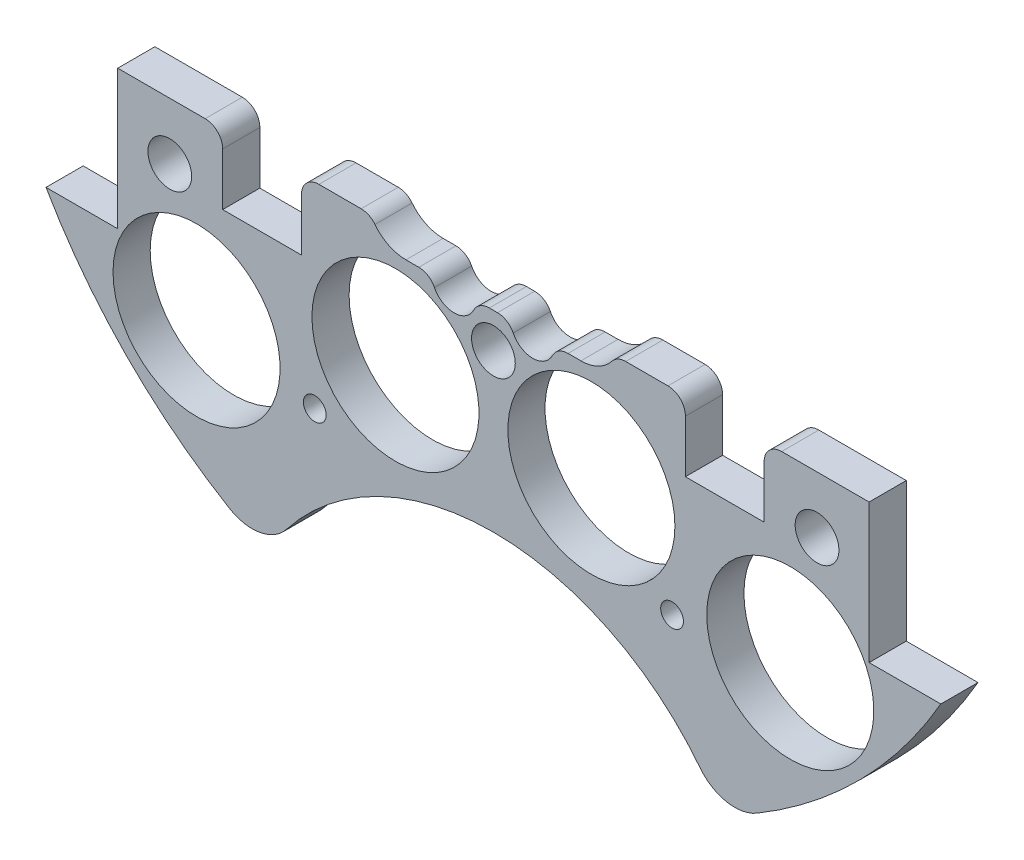
from build123d import *

# Parameters (mm, degrees)
SKETCH1_R                 = 1.651
BOSS_EXTRUDE2_DEPTH       = 5.3975
SKETCH2_R                 = 1.143
CUT_EXTRUDE1_DEPTH        = 6.3975
SKETCH3_R                 = 12.1285
CUT_EXTRUDE2_DEPTH        = 6.3975
SKETCH4_W                 = 28.562713242
SKETCH4_H                 = 11.677503754
BOSS_EXTRUDE3_DEPTH       = 5.3975
SKETCH5_W                 = 216.7214489
SKETCH5_H                 = 130.569220634
CUT_EXTRUDE4_DEPTH        = 6.3975
SKETCH6_R                 = 38.1
CUT_EXTRUDE5_DEPTH        = 60.96
FILLET1_R                 = 6.35
FILLET2_R                 = 6.35
SKETCH102_W               = 11.43
SKETCH102_H               = 10.16
CUT_EXTRUDE101_DEPTH      = 6.3975001
SKETCH158_R               = 1.651
CUT_EXTRUDE157_DEPTH      = 97.79
SKETCH212_R               = 3.175
CUT_EXTRUDE211_DEPTH      = 103.378
CUT_EXTRUDE211_DEPTH_BACK = 48.768
CUT_EXTRUDE104_DEPTH      = 10
FILLET3_R                 = 2.54


with BuildPart() as part:
    # Sketch1 → Boss-Extrude2 (new body)
    with BuildSketch(Plane.XY):
        with BuildLine():
            Line((-64.964441474, 37.338), (-54.550441474, 37.338))
            Line((-54.550441474, 37.338), (-54.550441474, -37.338))
            Line((-54.550441474, -37.338), (-64.964441474, -37.338))
            ThreePointArc((-64.964441474, -37.338), (0, -74.93), (64.964441474, -37.338))
            Line((64.964441474, -37.338), (54.550441474, -37.338))
            Line((54.550441474, -37.338), (54.550441474, 37.338))
            Line((54.550441474, 37.338), (64.964441474, 37.338))
            ThreePointArc((64.964441474, 37.338), (0, 74.93), (-64.964441474, 37.338))
        make_face()
        with Locations((-46.482, 11.049)):
            Circle(SKETCH1_R, mode=Mode.SUBTRACT)
        with Locations((-21.083270032, 10.795)):
            Circle(SKETCH1_R, mode=Mode.SUBTRACT)
        with Locations((-21.083270032, -10.795)):
            Circle(SKETCH1_R, mode=Mode.SUBTRACT)
        with Locations((-46.482, -11.049)):
            Circle(SKETCH1_R, mode=Mode.SUBTRACT)
        with Locations((46.482, -11.049)):
            Circle(SKETCH1_R, mode=Mode.SUBTRACT)
        with Locations((21.083270032, -10.795)):
            Circle(SKETCH1_R, mode=Mode.SUBTRACT)
        with Locations((21.083270032, 10.795)):
            Circle(SKETCH1_R, mode=Mode.SUBTRACT)
        with Locations((46.482, 11.049)):
            Circle(SKETCH1_R, mode=Mode.SUBTRACT)
    extrude(amount=BOSS_EXTRUDE2_DEPTH)

    # Sketch2 → Cut-Extrude1 (cut, through all)
    with BuildSketch(Plane.XY.offset(5.3975)):
        with Locations((-6.731, 62.23)):
            Circle(SKETCH2_R)
        with Locations((6.731, 62.23)):
            Circle(SKETCH2_R)
    extrude(amount=-CUT_EXTRUDE1_DEPTH, mode=Mode.SUBTRACT)

    # Sketch3 → Cut-Extrude2 (cut, through all)
    with BuildSketch(Plane(origin=(0, 0, 0), x_dir=(-1, 0, 0), z_dir=(0, 0, -1))):
        with Locations((-43.105229381, -43.105229381)):
            Circle(SKETCH3_R)
        with Locations((14.224, -34.29)):
            Circle(SKETCH3_R)
        with Locations((14.224, 34.29)):
            Circle(SKETCH3_R)
        with Locations((-43.105229381, 43.105229381)):
            Circle(SKETCH3_R)
        with Locations((43.105229381, 43.105229381)):
            Circle(SKETCH3_R)
        with Locations((-14.224, 34.29)):
            Circle(SKETCH3_R)
        with Locations((-14.224, -34.29)):
            Circle(SKETCH3_R)
        with Locations((43.105229381, -43.105229381)):
            Circle(SKETCH3_R)
    extrude(amount=-CUT_EXTRUDE2_DEPTH, mode=Mode.SUBTRACT)

    # Sketch4 → Boss-Extrude3 (add)
    with BuildSketch(Plane(origin=(0, 0, 0), x_dir=(-1, 0, 0), z_dir=(0, 0, -1))):
        with Locations((-1.488809975, 62.152540216)):
            Rectangle(SKETCH4_W, SKETCH4_H)
    extrude(amount=-BOSS_EXTRUDE3_DEPTH)

    # Sketch5 → Cut-Extrude4 (cut, through all)
    with BuildSketch(Plane(origin=(0, 0, 0), x_dir=(-1, 0, 0), z_dir=(0, 0, -1))):
        with Locations((23.316688373, 48.139610317)):
            Rectangle(SKETCH5_W, SKETCH5_H)
    extrude(amount=-CUT_EXTRUDE4_DEPTH, mode=Mode.SUBTRACT)

    # Sketch6 → Cut-Extrude5 (cut)
    with BuildSketch(Plane(origin=(0, 0, 0), x_dir=(-1, 0, 0), z_dir=(0, 0, -1))):
        with Locations((0, -86.312058398)):
            Circle(SKETCH6_R)
    extrude(amount=-CUT_EXTRUDE5_DEPTH, mode=Mode.SUBTRACT)

    # Fillet1
    fillet1_edges = [part.edges().sort_by_distance(p)[0] for p in [
        (-33.000960548, -67.271401821, 2.69875),
    ]]
    fillet(fillet1_edges, radius=FILLET1_R)

    # Fillet2
    fillet2_edges = [part.edges().sort_by_distance(p)[0] for p in [
        (33.000960548, -67.271401821, 2.69875),
    ]]
    fillet(fillet2_edges, radius=FILLET2_R)

    # Sketch102 → Cut-Extrude101 (cut, through all)
    with BuildSketch(Plane(origin=(0, 0, 0), x_dir=(-1, 0, 0), z_dir=(0, 0, -1))):
        with Locations((-33.595441474, -22.225)):
            Rectangle(SKETCH102_W, SKETCH102_H)
        with Locations((33.595441474, -22.225)):
            Rectangle(SKETCH102_W, SKETCH102_H)
    extrude(amount=-CUT_EXTRUDE101_DEPTH, mode=Mode.SUBTRACT)

    # Sketch158 → Cut-Extrude157 (cut)
    with BuildSketch(Plane(origin=(30.092005081, 4.08352975, -24.638), x_dir=(-1, 0, 0), z_dir=(0, 0, -1))):
        with Locations((4.154396091, -49.728759131)):
            Circle(SKETCH158_R)
        with Locations((56.02961407, -49.728759131)):
            Circle(SKETCH158_R)
    extrude(amount=-CUT_EXTRUDE157_DEPTH, mode=Mode.SUBTRACT)

    # Sketch212 → Cut-Extrude211 (cut, two sides)
    with BuildSketch(Plane(origin=(30.092005081, 4.08352975, 11.4935), x_dir=(-1, 0, 0), z_dir=(0, 0, -1))) as cut_extrude211_sk:
        with Locations((77.082005081, -29.48352975)):
            Circle(SKETCH212_R)
        with Locations((30.092005081, -29.48352975)):
            Circle(SKETCH212_R)
        with Locations((-16.897994919, -29.48352975)):
            Circle(SKETCH212_R)
    extrude(amount=CUT_EXTRUDE211_DEPTH, mode=Mode.SUBTRACT)
    extrude(cut_extrude211_sk.sketch, amount=-CUT_EXTRUDE211_DEPTH_BACK, mode=Mode.SUBTRACT)

    # Sketch105 → Cut-Extrude104 (cut)
    with BuildSketch(Plane(origin=(0, 0, 0), x_dir=(-1, 0, 0), z_dir=(0, 0, -1))):
        with BuildLine():
            Line((-12.7, -20.32), (-8.89, -20.32))
            ThreePointArc((-8.89, -20.32), (-5.715, -23.495), (-2.54, -20.32))
            Line((-2.54, -20.32), (2.54, -20.32))
            ThreePointArc((2.54, -20.32), (5.715, -23.495), (8.89, -20.32))
            Line((8.89, -20.32), (12.7, -20.32))
            ThreePointArc((12.7, -20.32), (18.415, -14.605), (12.7, -8.89))
            Line((12.7, -8.89), (-12.7, -8.89))
            ThreePointArc((-12.7, -8.89), (-18.415, -14.605), (-12.7, -20.32))
        make_face()
    extrude(amount=-CUT_EXTRUDE104_DEPTH, mode=Mode.SUBTRACT)

    # Fillet3
    fillet3_edges = [part.edges().sort_by_distance(p)[0] for p in [
        (39.310441474, -17.145, 2.69875),
        (27.880441474, -17.145, 2.69875),
        (-27.880441474, -17.145, 2.69875),
        (-39.310441474, -17.145, 2.69875),
        (17.81953367, -17.145, 2.69875),
        (-17.81953367, -17.145, 2.69875),
        (-8.89, -20.32, 2.69875),
        (-2.54, -20.32, 2.69875),
        (2.54, -20.32, 2.69875),
        (8.89, -20.32, 2.69875),
    ]]
    fillet(fillet3_edges, radius=FILLET3_R)


solid = part.part
